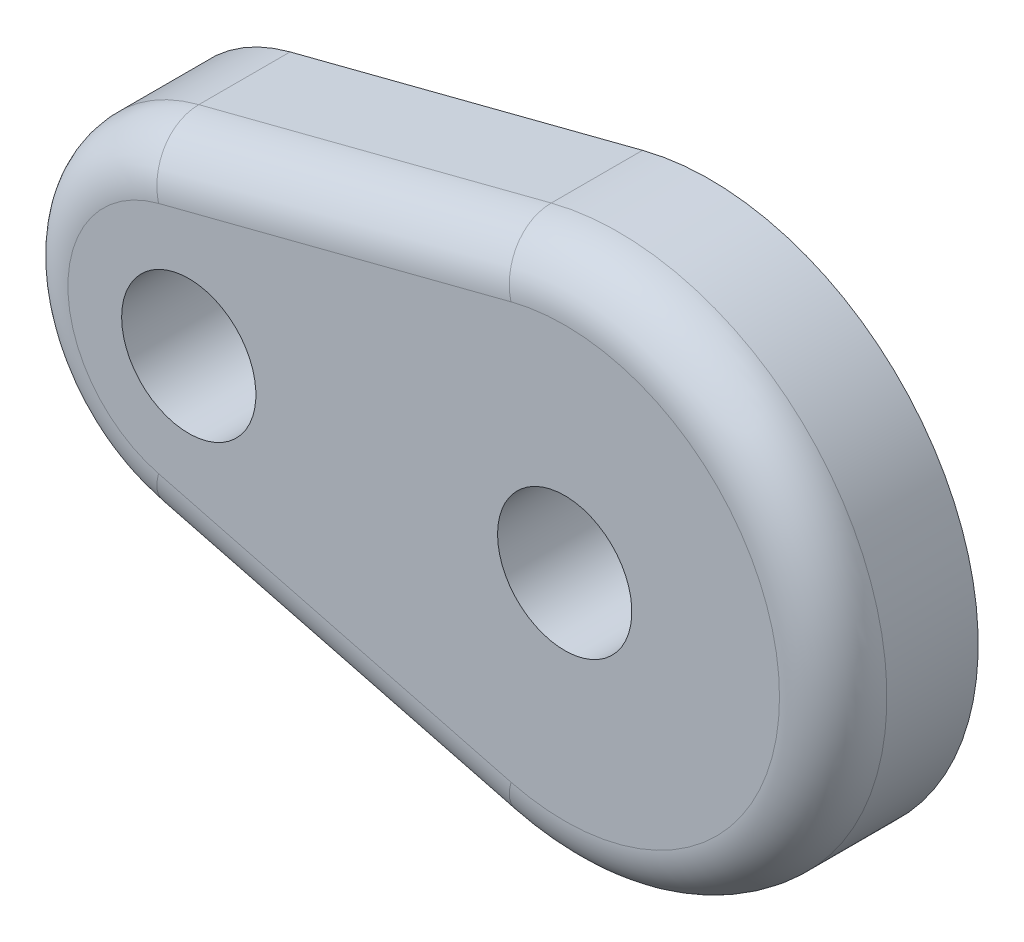
from build123d import *

# Parameters (mm, degrees)
BOSS_EXTRUDE1_DEPTH        = 4.7625
CUT_EXTRUDE1_DEPTH         = 1.3335
F_1_8_0_1250_DOWEL_HOLE1_D = 3.175
FILLET1_R                  = 1.27


with BuildPart() as part:
    # Sketch1 → Boss-Extrude1 (new body)
    with BuildSketch(Plane.XY):
        with BuildLine():
            Line((-9.921875, 3.99643469), (-1.5875, 6.148361062))
            ThreePointArc((-1.5875, 6.148361062), (6.35, 0), (-1.5875, -6.148361062))
            Line((-1.5875, -6.148361062), (-9.921875, -3.99643469))
            ThreePointArc((-9.921875, -3.99643469), (-13.0175, 0), (-9.921875, 3.99643469))
        make_face()
    extrude(amount=BOSS_EXTRUDE1_DEPTH)

    # Sketch2 → Cut-Extrude1 (cut)
    with BuildSketch(Plane(origin=(0, 0, 0), x_dir=(-1, 0, 0), z_dir=(0, 0, -1))):
        with BuildLine():
            Line((9.921875, 3.99643469), (1.5875, 6.148361062))
            ThreePointArc((1.5875, 6.148361062), (-6.35, 0), (1.5875, -6.148361062))
            Line((1.5875, -6.148361062), (9.921875, -3.99643469))
            ThreePointArc((9.921875, -3.99643469), (13.0175, 0), (9.921875, 3.99643469))
        make_face()
    extrude(amount=-CUT_EXTRUDE1_DEPTH, mode=Mode.SUBTRACT)

    # 1/8 (0.1250) Dowel Hole1 (through all)
    with Locations(Plane(origin=(0, 0, 1.3335), x_dir=(-1, 0, 0), z_dir=(0, 0, -1))):
        with Locations((8.89, 0), (0, 0)):
            Hole(F_1_8_0_1250_DOWEL_HOLE1_D / 2)

    # Fillet1
    fillet1_edges = [part.edges().sort_by_distance(p)[0] for p in [
        (6.35, 0, 4.7625),
        (-5.7546875, 5.072397876, 4.7625),
        (-13.0175, 0, 4.7625),
        (-5.7546875, -5.072397876, 4.7625),
    ]]
    fillet(fillet1_edges, radius=FILLET1_R)


solid = part.part
